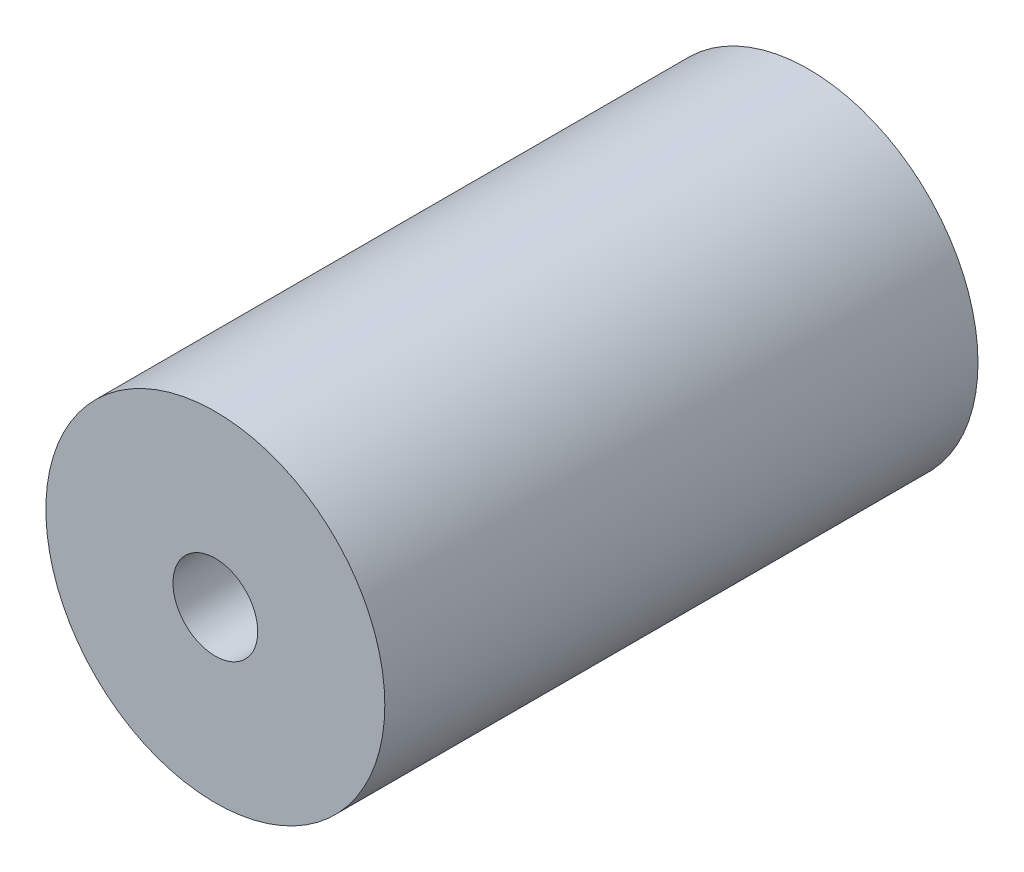
from build123d import *

# Parameters (mm, degrees)
CROQUIS1_R              = 10
CROQUIS1_R_2            = 2.5
SALIENTE_EXTRUIR1_DEPTH = 17.5


with BuildPart() as part:
    # Croquis1 → Saliente-Extruir1 (new body, symmetric)
    with BuildSketch(Plane.XY):
        Circle(CROQUIS1_R)
        Circle(CROQUIS1_R_2, mode=Mode.SUBTRACT)
    extrude(amount=SALIENTE_EXTRUIR1_DEPTH, both=True)


solid = part.part
